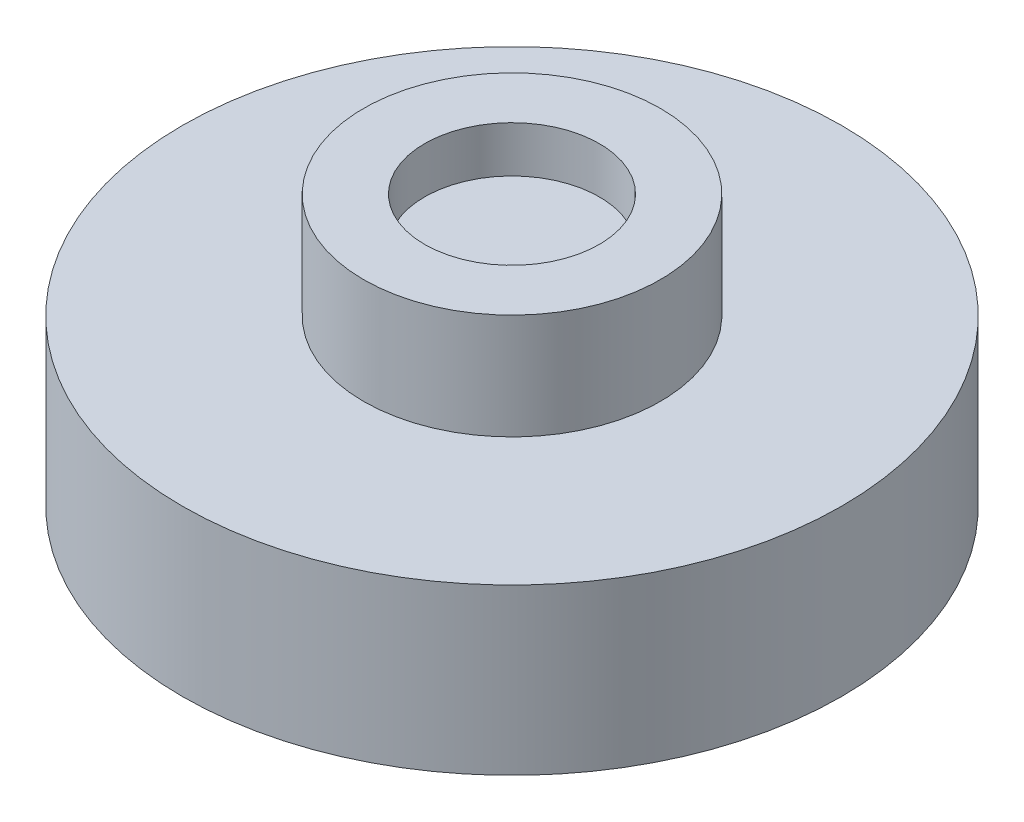
from build123d import *

# Parameters (mm, degrees)
SKETCH1_R           = 4.5
SKETCH1_R_2         = 2.65
BOSS_EXTRUDE1_DEPTH = 3.8
SKETCH2_R           = 2.65
BOSS_EXTRUDE2_DEPTH = 1.8
SKETCH3_R           = 10
BOSS_EXTRUDE3_DEPTH = 5
SKETCH4_R           = 6.809110127
CUT_EXTRUDE1_DEPTH  = 0.6


with BuildPart() as part:
    # Sketch1 → Boss-Extrude1 (new body)
    with BuildSketch(Plane(origin=(0, 0, 0), x_dir=(1, 0, 0), z_dir=(0, 1, 0))):
        Circle(SKETCH1_R)
        Circle(SKETCH1_R_2, mode=Mode.SUBTRACT)
    extrude(amount=BOSS_EXTRUDE1_DEPTH)

    # Sketch2 → Boss-Extrude2 (add)
    with BuildSketch(Plane.XZ):
        Circle(SKETCH2_R)
    extrude(amount=-BOSS_EXTRUDE2_DEPTH)

    # Sketch3 → Boss-Extrude3 (add)
    with BuildSketch(Plane.XZ):
        Circle(SKETCH3_R)
    extrude(amount=BOSS_EXTRUDE3_DEPTH)

    # Sketch4 → Cut-Extrude1 (cut)
    with BuildSketch(Plane(origin=(0, 3.8, 0), x_dir=(1, 0, 0), z_dir=(0, 1, 0))):
        Circle(SKETCH4_R)
    extrude(amount=-CUT_EXTRUDE1_DEPTH, mode=Mode.SUBTRACT)


solid = part.part
